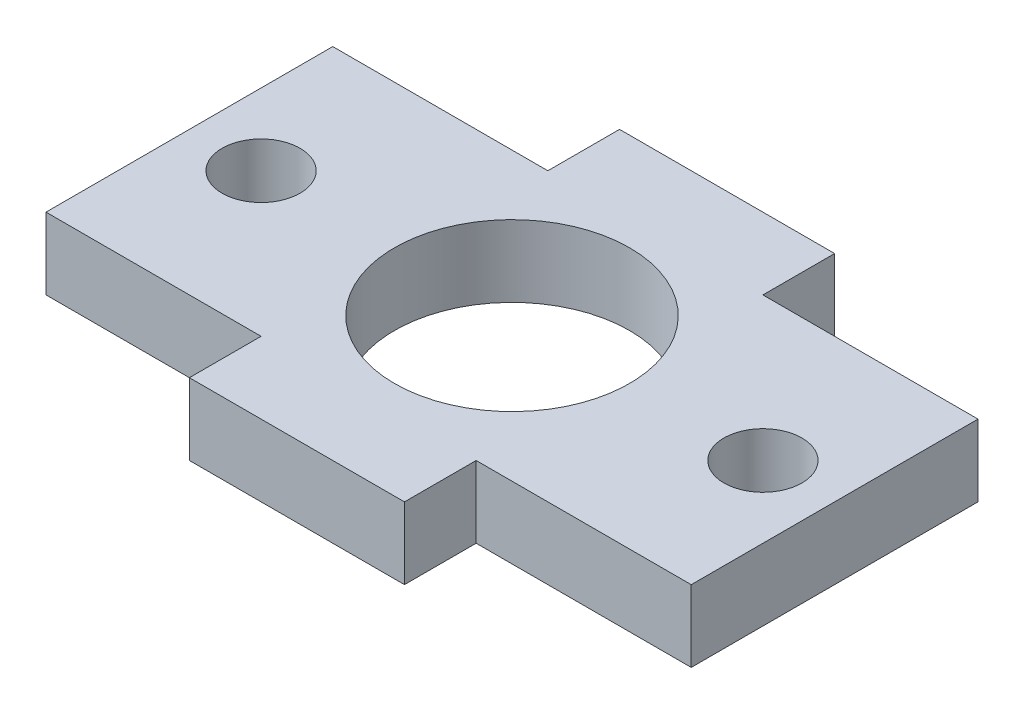
from build123d import *

# Parameters (mm, degrees)
SKETCH1_W           = 57.15
SKETCH1_H           = 25.4
SKETCH1_R           = 10.414
SKETCH1_R_2         = 3.4544
BOSS_EXTRUDE1_DEPTH = 6.35
SKETCH2_W           = 19.05
SKETCH2_H           = 6.35
BOSS_EXTRUDE2_DEPTH = 6.35


with BuildPart() as part:
    # Sketch1 → Boss-Extrude1 (new body)
    with BuildSketch(Plane(origin=(0, 0, 0), x_dir=(1, 0, 0), z_dir=(0, 1, 0))):
        Rectangle(SKETCH1_W, SKETCH1_H)
        Circle(SKETCH1_R, mode=Mode.SUBTRACT)
        with Locations((-22.225, 0)):
            Circle(SKETCH1_R_2, mode=Mode.SUBTRACT)
        with Locations((22.225, 0)):
            Circle(SKETCH1_R_2, mode=Mode.SUBTRACT)
    extrude(amount=BOSS_EXTRUDE1_DEPTH)

    # Sketch2 → Boss-Extrude2 (add)
    with BuildSketch(Plane(origin=(0, 6.35, 0), x_dir=(1, 0, 0), z_dir=(0, 1, 0))):
        with Locations((0, 15.875)):
            Rectangle(SKETCH2_W, SKETCH2_H)
    boss_extrude2 = extrude(amount=-BOSS_EXTRUDE2_DEPTH)

    # Mirror1: Boss-Extrude2 across plane
    add(boss_extrude2.mirror(Plane.XY))


solid = part.part
